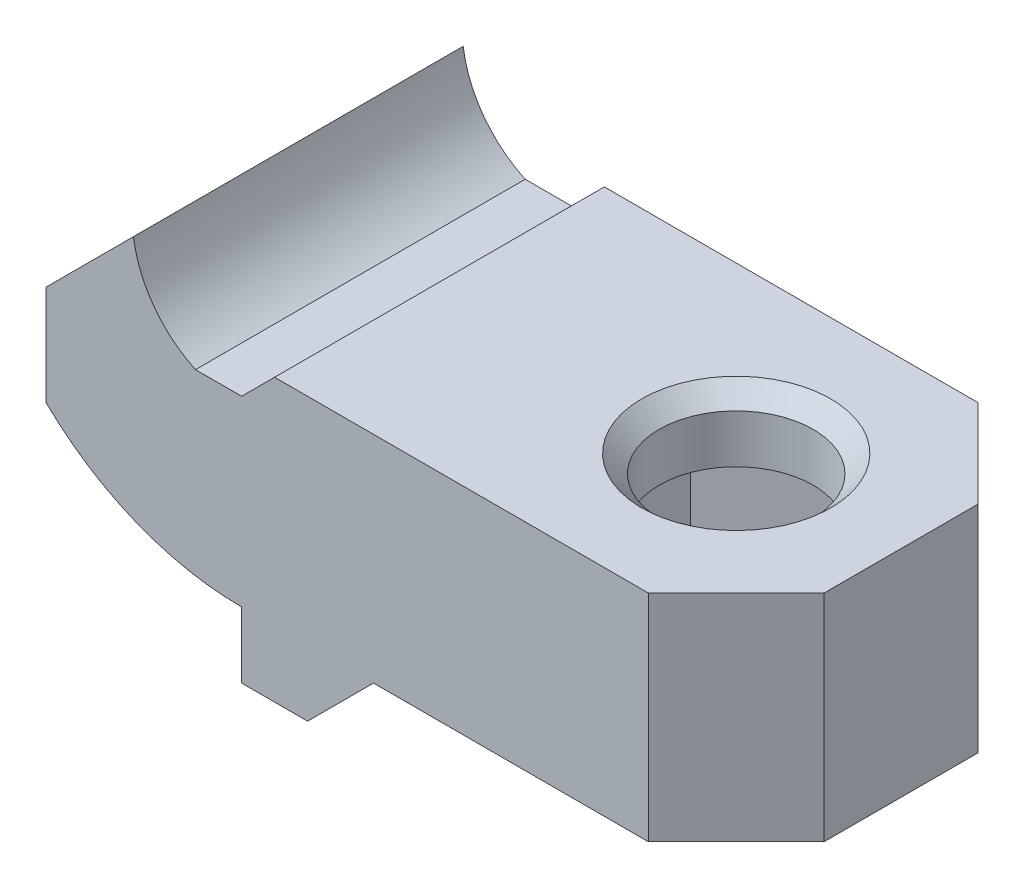
from build123d import *

# Parameters (mm, degrees)
SALIENTE_EXTRUIR1_DEPTH = 7.5
SALIENTE_EXTRUIR2_DEPTH = 15
CROQUIS7_R              = 3.5
CORTAR_EXTRUIR4_DEPTH   = 13.8
CORTAR_EXTRUIR5_START   = -3
CORTAR_EXTRUIR5_DEPTH   = 10
CHAFL_N4_SIZE           = 4
CHAFL_N5_SIZE           = 0.8


with BuildPart() as part:
    # Croquis1 → Saliente-Extruir1 (new body, symmetric)
    with BuildSketch(Plane.XY):
        with BuildLine():
            Line((-8.9, 4), (-4.920420362, 7.979579638))
            ThreePointArc((-4.920420362, 7.979579638), (-3.998499164, 5.705173276), (-2.1, 4.15))
            Line((-2.1, 4.15), (0, 4.15))
            Line((0, 4.15), (0, -4.15))
            ThreePointArc((0, -4.15), (-4.800362316, -3.215771009), (-8.9, -0.549456506))
            Line((-8.9, -0.549456506), (-8.9, 4))
        make_face()
    extrude(amount=SALIENTE_EXTRUIR1_DEPTH, both=True)

    # Croquis6 → Saliente-Extruir2 (add, through all)
    with BuildSketch(Plane(origin=(0, 0, -7.5), x_dir=(-1, 0, 0), z_dir=(0, 0, -1))):
        Polygon((0, -4.15), (0, -7.15), (-3, -7.15), (-6, -4.15), (-22.5, -4.15), (-22.5, 5.65), (-1.5, 5.65), (0, 4.15), align=None)
    extrude(amount=-SALIENTE_EXTRUIR2_DEPTH)

    # Croquis7 → Cortar-Extruir4 (cut, through all)
    with BuildSketch(Plane(origin=(0, 5.65, 0), x_dir=(1, 0, 0), z_dir=(0, 1, 0))):
        with Locations((15, 0)):
            Circle(CROQUIS7_R)
    extrude(amount=-CORTAR_EXTRUIR4_DEPTH, mode=Mode.SUBTRACT)

    # Croquis8 → Cortar-Extruir5 (cut)
    with BuildSketch(Plane(origin=(0, 5.65, 0), x_dir=(1, 0, 0), z_dir=(0, 1, 0)).offset(CORTAR_EXTRUIR5_START)):
        Polygon((15, 5.658032638), (10.1, 2.829016319), (10.1, -2.829016319), (15, -5.658032638), (19.9, -2.829016319), (19.9, 2.829016319), align=None)
    extrude(amount=-CORTAR_EXTRUIR5_DEPTH, mode=Mode.SUBTRACT)

    # Chaflán4
    chafl_n4_edges = [part.edges().sort_by_distance(p)[0] for p in [
        (22.5, 0.75, 7.5),
        (22.5, 0.75, -7.5),
    ]]
    chamfer(chafl_n4_edges, length=CHAFL_N4_SIZE)

    # Chaflán5
    chafl_n5_edges = [part.edges().sort_by_distance(p)[0] for p in [
        (11.5, 5.65, 0),
        (12.55, -4.15, -4.243524479),
        (10.1, -4.15, 0),
        (12.55, -4.15, 4.243524479),
        (17.45, -4.15, 4.243524479),
        (19.9, -4.15, 0),
        (17.45, -4.15, -4.243524479),
    ]]
    chamfer(chafl_n5_edges, length=CHAFL_N5_SIZE)


solid = part.part
